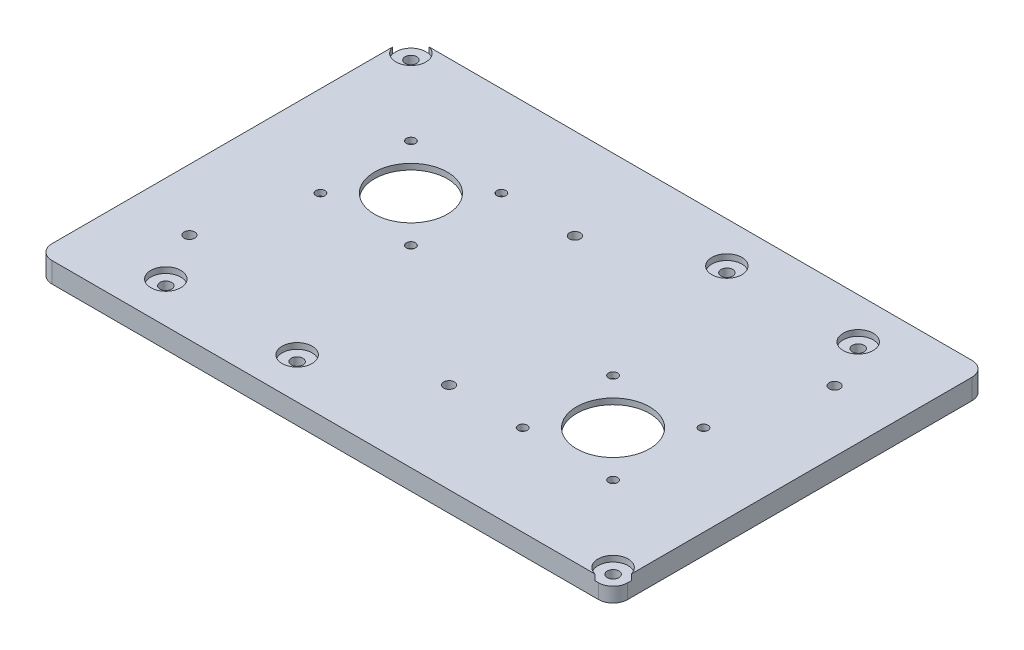
from build123d import *

# Parameters (mm, degrees)
SKETCH1_R           = 2
SKETCH1_W           = 43
SKETCH1_H           = 43
BOSS_EXTRUDE1_DEPTH = 7
SKETCH2_W           = 43
SKETCH2_H           = 43
SKETCH2_R           = 12.5
SKETCH2_R_2         = 1.55
BOSS_EXTRUDE2_DEPTH = 2
SKETCH3_W           = 51
SKETCH3_H           = 51
SKETCH3_W_2         = 43
SKETCH3_H_2         = 43
BOSS_EXTRUDE3_DEPTH = 4
SKETCH4_R           = 5.15
CUT_EXTRUDE1_DEPTH  = 2
SKETCH5_R           = 1.85
CUT_EXTRUDE2_DEPTH  = 10


with BuildPart() as part:
    # Sketch1 → Boss-Extrude1 (new body)
    with BuildSketch(Plane(origin=(0, 0, 0), x_dir=(1, 0, 0), z_dir=(0, 1, 0))):
        with BuildLine():
            Line((-132.651439051, 63.421561199), (54.631829022, 63.421561199))
            ThreePointArc((54.631829022, 63.421561199), (58.167362928, 61.957095105), (59.631829022, 58.421561199))
            Line((59.631829022, 58.421561199), (59.631829022, -59.578438801))
            ThreePointArc((59.631829022, -59.578438801), (58.167362928, -63.113972707), (54.631829022, -64.578438801))
            Line((54.631829022, -64.578438801), (-132.651439051, -64.578438801))
            ThreePointArc((-132.651439051, -64.578438801), (-136.186972957, -63.113972707), (-137.651439051, -59.578438801))
            Line((-137.651439051, -59.578438801), (-137.651439051, 58.421561199))
            ThreePointArc((-137.651439051, 58.421561199), (-136.186972957, 61.957095105), (-132.651439051, 63.421561199))
        make_face()
        with Locations((-132.651439051, 58.421561199)):
            Circle(SKETCH1_R, mode=Mode.SUBTRACT)
        with Locations((54.631829022, -59.578438801)):
            Circle(SKETCH1_R, mode=Mode.SUBTRACT)
        with Locations((29.631829022, 49.421561199)):
            Circle(SKETCH1_R, mode=Mode.SUBTRACT)
        with Locations((-15.368170978, 49.421561199)):
            Circle(SKETCH1_R, mode=Mode.SUBTRACT)
        with Locations((-107.651439051, -50.578438801)):
            Circle(SKETCH1_R, mode=Mode.SUBTRACT)
        with Locations((-62.651439051, -50.578438801)):
            Circle(SKETCH1_R, mode=Mode.SUBTRACT)
        with Locations((-91.151439051, 16.921561199)):
            Rectangle(SKETCH1_W, SKETCH1_H, mode=Mode.SUBTRACT)
        with Locations((13.131829022, -18.078438801)):
            Rectangle(SKETCH1_W, SKETCH1_H, mode=Mode.SUBTRACT)
    extrude(amount=BOSS_EXTRUDE1_DEPTH)

    # Sketch2 → Boss-Extrude2 (add)
    with BuildSketch(Plane(origin=(0, 7, 0), x_dir=(1, 0, 0), z_dir=(0, 1, 0))):
        with Locations((-91.151439051, 16.921561199)):
            Rectangle(SKETCH2_W, SKETCH2_H)
        with Locations((-91.151439051, 16.921561199)):
            Circle(SKETCH2_R, mode=Mode.SUBTRACT)
        with Locations((-106.651439051, 32.421561199)):
            Circle(SKETCH2_R_2, mode=Mode.SUBTRACT)
        with Locations((-75.651439051, 32.421561199)):
            Circle(SKETCH2_R_2, mode=Mode.SUBTRACT)
        with Locations((-75.651439051, 1.421561199)):
            Circle(SKETCH2_R_2, mode=Mode.SUBTRACT)
        with Locations((-106.651439051, 1.421561199)):
            Circle(SKETCH2_R_2, mode=Mode.SUBTRACT)
        with Locations((13.131829022, -18.078438801)):
            Rectangle(SKETCH2_W, SKETCH2_H)
        with Locations((13.131829022, -18.078438801)):
            Circle(SKETCH2_R, mode=Mode.SUBTRACT)
        with Locations((28.631829022, -33.578438801)):
            Circle(SKETCH2_R_2, mode=Mode.SUBTRACT)
        with Locations((-2.368170978, -33.578438801)):
            Circle(SKETCH2_R_2, mode=Mode.SUBTRACT)
        with Locations((-2.368170978, -2.578438801)):
            Circle(SKETCH2_R_2, mode=Mode.SUBTRACT)
        with Locations((28.631829022, -2.578438801)):
            Circle(SKETCH2_R_2, mode=Mode.SUBTRACT)
    extrude(amount=-BOSS_EXTRUDE2_DEPTH)

    # Sketch3 → Boss-Extrude3 (add)
    with BuildSketch(Plane.XZ):
        with Locations((13.131829022, 18.078438801)):
            Rectangle(SKETCH3_W, SKETCH3_H)
        with Locations((13.131829022, 18.078438801)):
            Rectangle(SKETCH3_W_2, SKETCH3_H_2, mode=Mode.SUBTRACT)
        with Locations((-91.151439051, -16.921561199)):
            Rectangle(SKETCH3_W, SKETCH3_H)
        with Locations((-91.151439051, -16.921561199)):
            Rectangle(SKETCH3_W_2, SKETCH3_H_2, mode=Mode.SUBTRACT)
    extrude(amount=BOSS_EXTRUDE3_DEPTH)

    # Sketch4 → Cut-Extrude1 (cut)
    with BuildSketch(Plane(origin=(0, 7, 0), x_dir=(1, 0, 0), z_dir=(0, 1, 0))):
        with Locations((-132.651439051, 58.421561199)):
            Circle(SKETCH4_R)
        with Locations((-15.368170978, 49.421561199)):
            Circle(SKETCH4_R)
        with Locations((29.631829022, 49.421561199)):
            Circle(SKETCH4_R)
        with Locations((54.631829022, -59.578438801)):
            Circle(SKETCH4_R)
        with Locations((-62.651439051, -50.578438801)):
            Circle(SKETCH4_R)
        with Locations((-107.651439051, -50.578438801)):
            Circle(SKETCH4_R)
    extrude(amount=-CUT_EXTRUDE1_DEPTH, mode=Mode.SUBTRACT)

    # Sketch5 → Cut-Extrude2 (cut)
    with BuildSketch(Plane.XZ):
        with Locations((-116.651439051, 33.49401297)):
            Circle(SKETCH5_R)
        with Locations((-27.651439051, 33.49401297)):
            Circle(SKETCH5_R)
        with Locations((-50.368170978, -32.337135367)):
            Circle(SKETCH5_R)
        with Locations((38.631829022, -32.337135367)):
            Circle(SKETCH5_R)
    extrude(amount=-CUT_EXTRUDE2_DEPTH, mode=Mode.SUBTRACT)


solid = part.part
